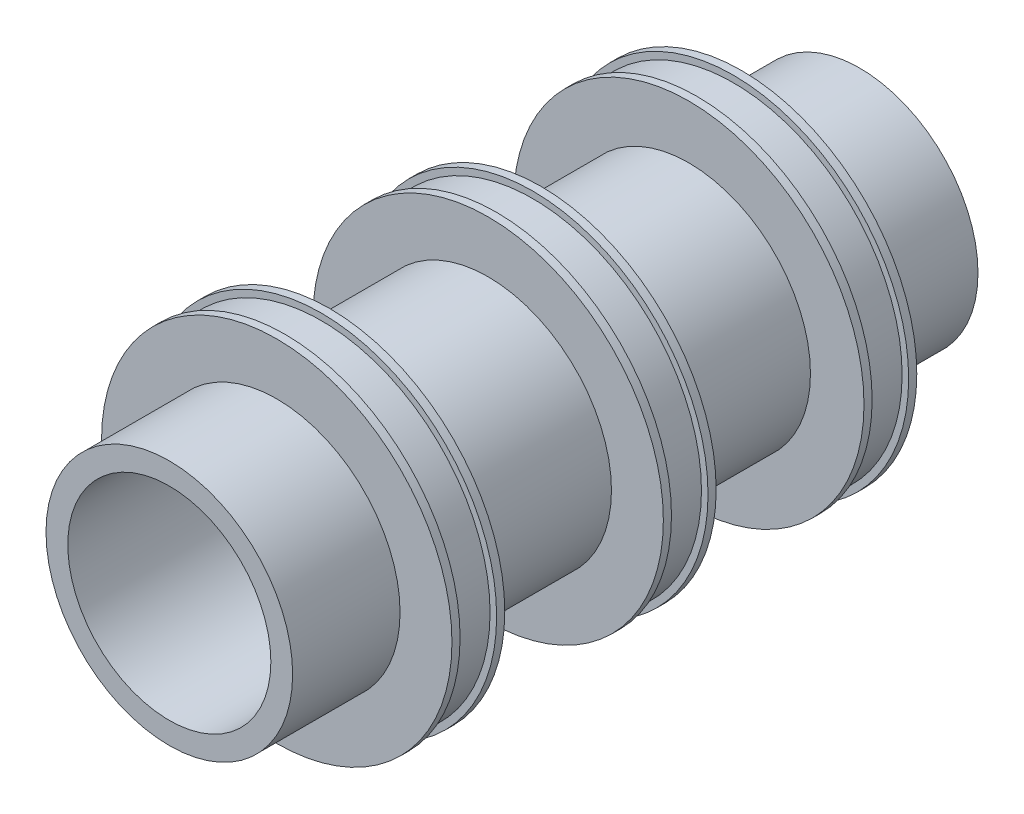
from build123d import *


with BuildPart() as part:
    # Sketch1 → Revolve2 (revolve)
    with BuildSketch(Plane(origin=(0, 0, 0), x_dir=(0, 0, -1), z_dir=(1, 0, 0))):
        Polygon((-85, 25), (85, 25), (85, 29.115175046), (55.901270972, 29.115175046), (55.901270972, 43.144153468), (53.901270972, 43.144153468), (53.901270972, 41.530001869), (44.901270972, 41.530001869), (44.901270972, 43.144153468), (42.901270972, 43.144153468), (42.901270972, 29.961940535), (6.5, 29.961940535), (6.5, 43.144153468), (4.5, 43.144153468), (4.5, 41.530001869), (-4.5, 41.530001869), (-4.5, 43.144153468), (-6.5, 43.144153468), (-6.5, 30.363940149), (-45.552167267, 30.363940149), (-45.552167267, 43.144153468), (-47.552167267, 43.144153468), (-47.552167267, 41.530001869), (-56.552167267, 41.530001869), (-56.552167267, 43.144153468), (-58.552167267, 43.144153468), (-58.552167267, 30.363940149), (-85, 30.363940149), align=None)
    revolve(axis=Axis((0, 0, 119.060774984), (0, 0, -1)))


solid = part.part
